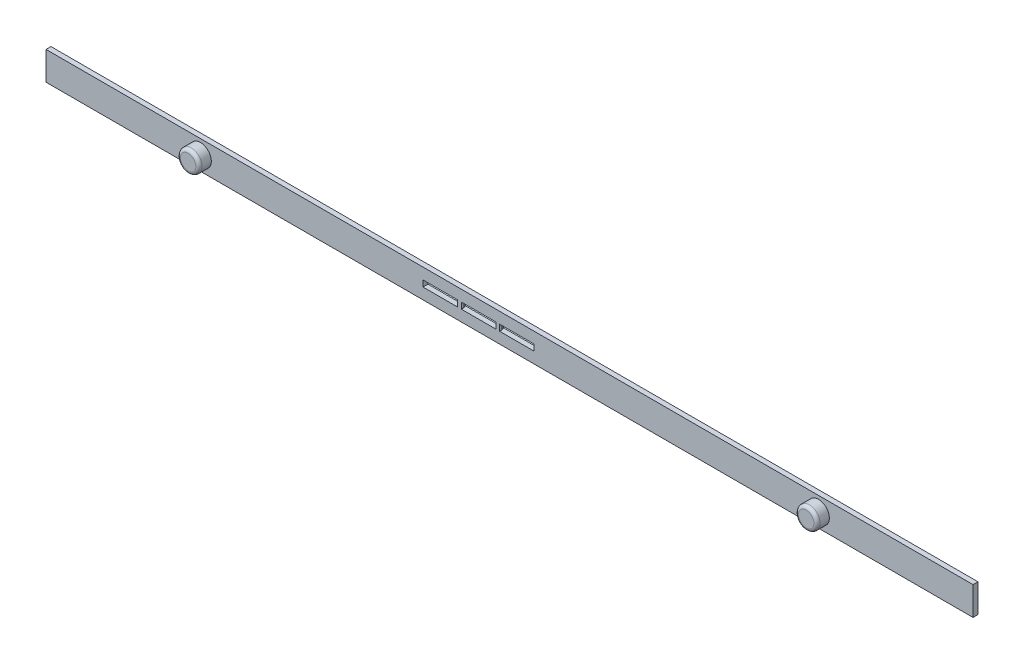
from build123d import *

# Parameters (mm, degrees)
SKICA2_W                = 150
SKICA2_H                = 4.6
SKICA2_W_2              = 18
SKICA2_H_2              = 1
P_IDAT_VYSUNUT_M2_DEPTH = 0.8
SKICA3_R                = 1.75
P_IDAT_VYSUNUT_M3_DEPTH = 2
ZAOBLIT1_R              = 0.5
SKICA4_W                = 0.6
SKICA4_H                = 1
P_IDAT_VYSUNUT_M4_DEPTH = 0.8
ZKOSEN_1_SIZE           = 0.4
ZKOSEN_1_SIZE2          = 0.145588094
ZKOSEN_1_PART_2_SIZE    = 0.4
ZKOSEN_1_PART_2_SIZE2   = 0.145588094
ZKOSEN_1_PART_3_SIZE    = 0.4
ZKOSEN_1_PART_3_SIZE2   = 0.145588094
ZKOSEN_1_PART_4_SIZE    = 0.4
ZKOSEN_1_PART_4_SIZE2   = 0.145588094


with BuildPart() as part:
    # Skica2 → Přidat vysunutím2 (new body)
    with BuildSketch(Plane.XY):
        Rectangle(SKICA2_W, SKICA2_H)
        with Locations((-5, 0)):
            Rectangle(SKICA2_W_2, SKICA2_H_2, mode=Mode.SUBTRACT)
    extrude(amount=P_IDAT_VYSUNUT_M2_DEPTH)

    # Skica3 → Přidat vysunutím3 (add)
    with BuildSketch(Plane.XY.offset(0.8)):
        with Locations((-50, 0)):
            Circle(SKICA3_R)
        with Locations((50, 0)):
            Circle(SKICA3_R)
    extrude(amount=P_IDAT_VYSUNUT_M3_DEPTH)

    # Zaoblit1
    zaoblit1_edges = [part.edges().sort_by_distance(p)[0] for p in [
        (-51.75, 0, 2.8),
        (48.25, 0, 2.8),
    ]]
    fillet(zaoblit1_edges, radius=ZAOBLIT1_R)

    # Skica4 → Přidat vysunutím4 (add)
    with BuildSketch(Plane(origin=(0, 0, 0), x_dir=(-1, 0, 0), z_dir=(0, 0, -1))):
        with Locations((1.9, 0)):
            Rectangle(SKICA4_W, SKICA4_H)
        with Locations((8.1, 0)):
            Rectangle(SKICA4_W, SKICA4_H)
    extrude(amount=-P_IDAT_VYSUNUT_M4_DEPTH)

    # Zkosení1
    zkosen_1_edges = [part.edges().sort_by_distance(p)[0] for p in [
        (-1.6, 0, 0),
    ]]
    zkosen_1_side = [part.faces().sort_by_distance(p)[0] for p in [
        (-1.6, 0, 0.4),
    ]]
    chamfer(zkosen_1_edges, length=ZKOSEN_1_SIZE, length2=ZKOSEN_1_SIZE2, reference=zkosen_1_side[0])

    # Zkosení1 part 2
    zkosen_1_part_2_edges = [part.edges().sort_by_distance(p)[0] for p in [
        (-2.2, 0, 0),
    ]]
    zkosen_1_part_2_side = [part.faces().sort_by_distance(p)[0] for p in [
        (-2.2, 0, 0.4),
    ]]
    chamfer(zkosen_1_part_2_edges, length=ZKOSEN_1_PART_2_SIZE, length2=ZKOSEN_1_PART_2_SIZE2, reference=zkosen_1_part_2_side[0])

    # Zkosení1 part 3
    zkosen_1_part_3_edges = [part.edges().sort_by_distance(p)[0] for p in [
        (-8.4, 0, 0),
    ]]
    zkosen_1_part_3_side = [part.faces().sort_by_distance(p)[0] for p in [
        (-8.4, 0, 0.4),
    ]]
    chamfer(zkosen_1_part_3_edges, length=ZKOSEN_1_PART_3_SIZE, length2=ZKOSEN_1_PART_3_SIZE2, reference=zkosen_1_part_3_side[0])

    # Zkosení1 part 4
    zkosen_1_part_4_edges = [part.edges().sort_by_distance(p)[0] for p in [
        (-7.8, 0, 0),
    ]]
    zkosen_1_part_4_side = [part.faces().sort_by_distance(p)[0] for p in [
        (-7.8, 0, 0.4),
    ]]
    chamfer(zkosen_1_part_4_edges, length=ZKOSEN_1_PART_4_SIZE, length2=ZKOSEN_1_PART_4_SIZE2, reference=zkosen_1_part_4_side[0])


solid = part.part
